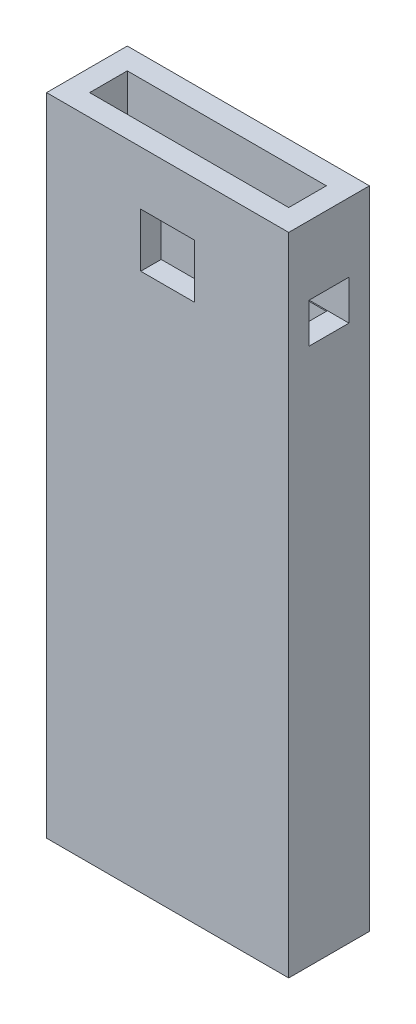
from build123d import *

# Parameters (mm, degrees)
SKETCH1_W                 = 45
SKETCH1_H                 = 15
BOSS_EXTRUDE1_DEPTH       = 60
SHELL1_T                  = -4
SHELL1_THICKNESS_2_FACE_W = 7
SHELL1_THICKNESS_2_FACE_H = 37
SHELL1_THICKNESS_2_DEPTH  = 2
SKETCH3_W                 = 10
SKETCH3_H                 = 7
CUT_EXTRUDE2_DEPTH        = 4
CUT_EXTRUDE3_REACH        = 67.812
SKETCH4_W                 = 10
SKETCH4_H                 = 10
SKETCH5_W                 = 7.4
SKETCH5_H                 = 7.4
CUT_EXTRUDE4_DEPTH        = 76.374067158
CUT_EXTRUDE5_START        = -1.2
CUT_EXTRUDE5_DEPTH        = 3.6
CUT_EXTRUDE6_REACH        = 124.321
SKETCH7_R                 = 2.1


with BuildPart() as part:
    # Sketch1 → Boss-Extrude1 (new, symmetric)
    with BuildSketch(Plane(origin=(0, 0, 0), x_dir=(1, 0, 0), z_dir=(0, 1, 0))):
        Rectangle(SKETCH1_W, SKETCH1_H)
    extrude(amount=BOSS_EXTRUDE1_DEPTH, both=True)

    # Shell1
    shell1_openings = [part.faces().sort_by_distance(p)[0] for p in [
        (0, 60, 0),
    ]]
    offset(amount=SHELL1_T, openings=shell1_openings, kind=Kind.INTERSECTION)

    # Shell1 thickness 2 face (on inner face of the shell) → Shell1 thickness 2 (add)
    with BuildSketch(Plane(origin=(0, -56, 0), x_dir=(0, 0, -1), z_dir=(0, -1, 0))):
        Rectangle(SHELL1_THICKNESS_2_FACE_W, SHELL1_THICKNESS_2_FACE_H)
    extrude(amount=-SHELL1_THICKNESS_2_DEPTH)

    # Sketch3 → Cut-Extrude2 (cut)
    with BuildSketch(Plane.XZ.offset(60)):
        Rectangle(SKETCH3_W, SKETCH3_H)
    extrude(amount=-CUT_EXTRUDE2_DEPTH, mode=Mode.SUBTRACT)

    # Sketch4 → Cut-Extrude3 (cut, up to next)
    with BuildSketch(Plane.XY.offset(7.5), mode=Mode.PRIVATE) as cut_extrude3_sk1:
        with Locations((0, 45)):
            Rectangle(SKETCH4_W, SKETCH4_H)
    cut_extrude3_tool1 = extrude(cut_extrude3_sk1.sketch, amount=-CUT_EXTRUDE3_REACH, mode=Mode.PRIVATE) & part.part
    add(cut_extrude3_tool1.solids().sort_by_distance((0, 45, 7.5))[0], mode=Mode.SUBTRACT)

    # Sketch5 → Cut-Extrude4 (cut, through all)
    with BuildSketch(Plane(origin=(22.5, 0, 0), x_dir=(0, 0, -1), z_dir=(1, 0, 0))):
        with Locations((0, 43.5)):
            Rectangle(SKETCH5_W, SKETCH5_H)
    extrude(amount=-CUT_EXTRUDE4_DEPTH, mode=Mode.SUBTRACT)

    # Sketch6 → Cut-Extrude5 (cut)
    with BuildSketch(Plane.XZ.offset(60).offset(CUT_EXTRUDE5_START)):
        Polygon((-15, 4.272391992), (-18.7, 2.136195996), (-18.7, -2.136195996), (-15, -4.272391992), (-11.3, -2.136195996), (-11.3, 2.136195996), align=None)
        Polygon((11.3, 2.136195996), (15, 4.272391992), (18.7, 2.136195996), (18.7, -2.136195996), (15, -4.272391992), (11.3, -2.136195996), align=None)
    extrude(amount=-CUT_EXTRUDE5_DEPTH, mode=Mode.SUBTRACT)

    # Sketch7 → Cut-Extrude6 (cut, up to next)
    with BuildSketch(Plane.XZ.offset(60), mode=Mode.PRIVATE) as cut_extrude6_sk1:
        with Locations(Location((-15, 0, 0), (0, 0, 270))):
            Circle(SKETCH7_R)
    cut_extrude6_tool1 = extrude(cut_extrude6_sk1.sketch, amount=-CUT_EXTRUDE6_REACH, mode=Mode.PRIVATE) & part.part
    # Sketch7 → Cut-Extrude6 (cut, up to next)
    with BuildSketch(Plane.XZ.offset(60), mode=Mode.PRIVATE) as cut_extrude6_sk2:
        with Locations(Location((15, 0, 0), (0, 0, 90))):
            Circle(SKETCH7_R)
    cut_extrude6_tool2 = extrude(cut_extrude6_sk2.sketch, amount=-CUT_EXTRUDE6_REACH, mode=Mode.PRIVATE) & part.part
    add(cut_extrude6_tool1.solids().sort_by_distance((-15, -60, 0))[0], mode=Mode.SUBTRACT)
    add(cut_extrude6_tool2.solids().sort_by_distance((15, -60, 0))[0], mode=Mode.SUBTRACT)


solid = part.part
